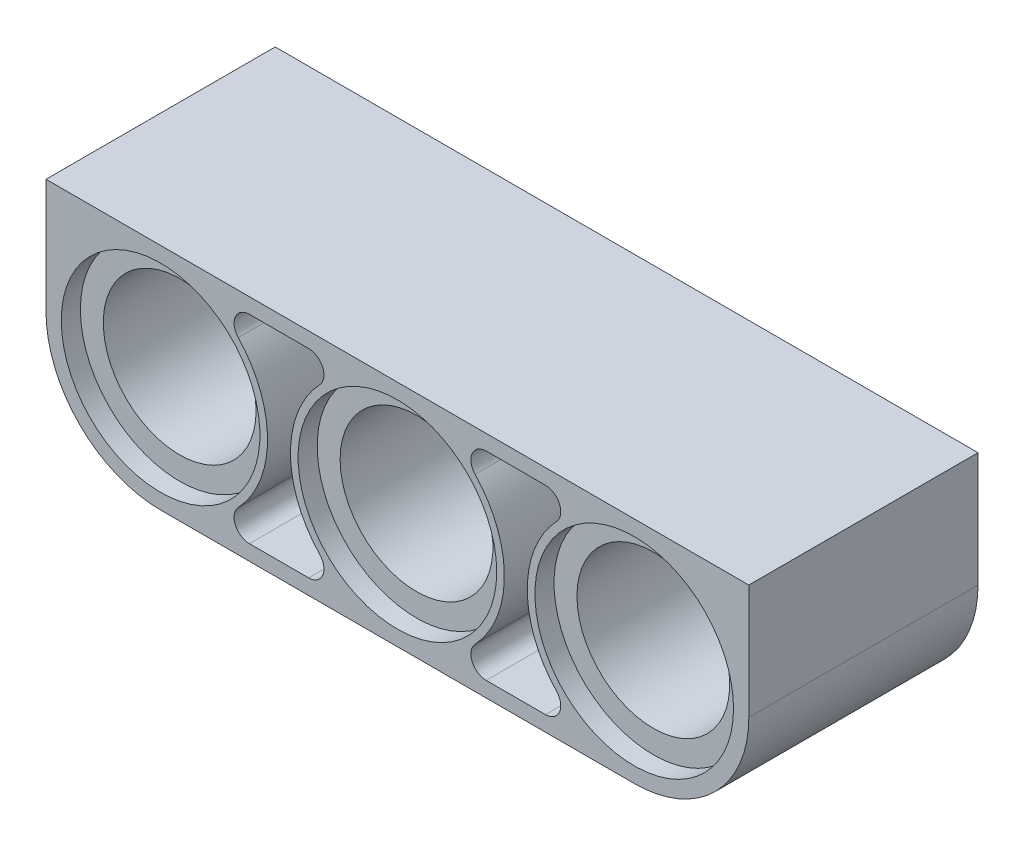
from build123d import *

# Parameters (mm, degrees)
SKETCH1_R           = 3.302
SKETCH1_R_2         = 2.54
BOSS_EXTRUDE1_DEPTH = 3.81
SKETCH1_7_R         = 2.54
BOSS_EXTRUDE2_DEPTH = 3.81
SKETCH2_R           = 3.302
CUT_EXTRUDE1_DEPTH  = 0.635
BOSS_EXTRUDE3_DEPTH = 7.62


with BuildPart() as part:
    # Sketch1 → Boss-Extrude1 (new body)
    with BuildSketch(Plane.XY):
        with BuildLine():
            Line((3.937, -3.81), (7.874, -3.81))
            ThreePointArc((7.874, -3.81), (11.684, 0), (7.874, 3.81))
            Line((7.874, 3.81), (3.937, 3.81))
            Line((3.937, 3.81), (3.937, 3.302))
            Line((3.937, 3.302), (4.92278669, 3.302))
            ThreePointArc((4.92278669, 3.302), (5.389414486, 2.994804631), (5.291688354, 2.44475))
            ThreePointArc((5.291688354, 2.44475), (4.318, 0), (5.291688354, -2.44475))
            ThreePointArc((5.291688354, -2.44475), (5.389414486, -2.994804631), (4.92278669, -3.302))
            Line((4.92278669, -3.302), (3.937, -3.302))
            Line((3.937, -3.302), (3.937, -3.81))
        make_face()
        with Locations((7.874, 0)):
            Circle(SKETCH1_R, mode=Mode.SUBTRACT)
        with Locations((7.874, 0)):
            Circle(SKETCH1_R)
        with Locations(Location((7.874, 0, 0), (0, 0, 180))):
            Circle(SKETCH1_R_2, mode=Mode.SUBTRACT)
    extrude(amount=BOSS_EXTRUDE1_DEPTH)


with BuildPart() as body_2:
    # Sketch1_7 → Boss-Extrude2 (new body)
    with BuildSketch(Plane.XY):
        with BuildLine():
            Line((3.937, -3.81), (3.937, -3.302))
            Line((3.937, -3.302), (2.95121331, -3.302))
            ThreePointArc((2.95121331, -3.302), (2.484585514, -2.994804631), (2.582311646, -2.44475))
            ThreePointArc((2.582311646, -2.44475), (3.556, 0), (2.582311646, 2.44475))
            ThreePointArc((2.582311646, 2.44475), (2.484585514, 2.994804631), (2.95121331, 3.302))
            Line((2.95121331, 3.302), (3.937, 3.302))
            Line((3.937, 3.302), (3.937, 3.81))
            Line((3.937, 3.81), (-3.937, 3.81))
            Line((-3.937, 3.81), (-3.937, 3.302))
            Line((-3.937, 3.302), (-2.95121331, 3.302))
            ThreePointArc((-2.95121331, 3.302), (-2.484585514, 2.994804631), (-2.582311646, 2.44475))
            ThreePointArc((-2.582311646, 2.44475), (-3.556, 0), (-2.582311646, -2.44475))
            ThreePointArc((-2.582311646, -2.44475), (-2.484585514, -2.994804631), (-2.95121331, -3.302))
            Line((-2.95121331, -3.302), (-3.937, -3.302))
            Line((-3.937, -3.302), (-3.937, -3.81))
            Line((-3.937, -3.81), (3.937, -3.81))
        make_face()
        with Locations(Location((0, 0, 0), (0, 0, 180))):
            Circle(SKETCH1_7_R, mode=Mode.SUBTRACT)
    extrude(amount=BOSS_EXTRUDE2_DEPTH)


with BuildPart() as cut_extrude1_tool:
    # Sketch2 → Cut-Extrude1 (new body)
    with BuildSketch(Plane.XY):
        with Locations((7.874, 0)):
            Circle(SKETCH2_R)
        Circle(SKETCH2_R)
    extrude(amount=CUT_EXTRUDE1_DEPTH)


with BuildPart() as part_1:
    add(part.part)

    # Cut-Extrude1: cut by cut_extrude1_tool
    add(cut_extrude1_tool.part, mode=Mode.SUBTRACT)


with BuildPart() as body_2_1:
    add(body_2.part)

    # Cut-Extrude1: cut by cut_extrude1_tool
    add(cut_extrude1_tool.part, mode=Mode.SUBTRACT)


with BuildPart() as body_3:
    # Mirror2: mirrored copy
    add(part_1.part.mirror(Plane(origin=(0, 0, 0), x_dir=(0, 0, 1), z_dir=(1, 0, 0))))


with BuildPart() as part_2:
    add(part_1.part)

    # Combine1: union body 3, body 2
    add(body_3.part)
    add(body_2_1.part)

    # Mirror3: part across plane


with BuildPart() as part_3:
    add(part_2.part)
    add(part_2.part.mirror(Plane.XY.offset(3.81)))

    # Sketch3 → Boss-Extrude3 (add, through all)
    with BuildSketch(Plane.XY.offset(7.62)):
        with BuildLine():
            Line((7.874, 3.81), (11.684, 3.81))
            Line((11.684, 3.81), (11.684, 0))
            ThreePointArc((11.684, 0), (10.568076836, 2.694076836), (7.874, 3.81))
        make_face()
    boss_extrude3 = extrude(amount=-BOSS_EXTRUDE3_DEPTH)

    # Mirror4: Boss-Extrude3 across plane
    add(boss_extrude3.mirror(Plane(origin=(0, 0, 0), x_dir=(0, 0, 1), z_dir=(1, 0, 0))))


solid = part_3.part
